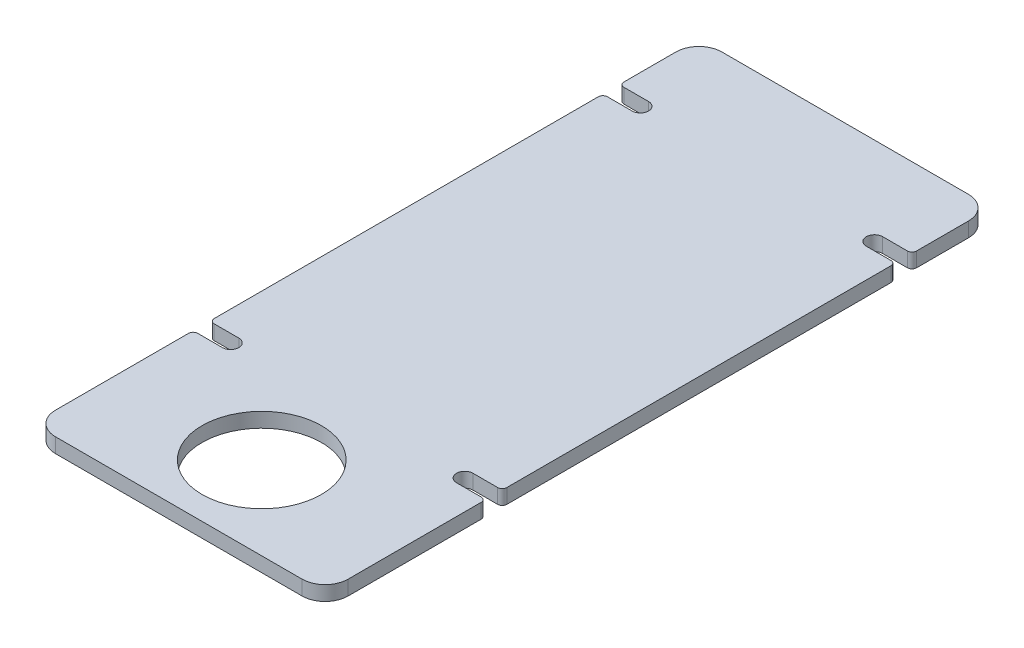
from build123d import *

# Parameters (mm, degrees)
SKETCH1_W           = 127
SKETCH1_H           = 289.2
SKETCH1_R           = 25.9
BOSS_EXTRUDE1_DEPTH = 6.35
CUT_EXTRUDE1_DEPTH  = 7.35
FILLET1_R           = 2
FILLET2_R           = 10


with BuildPart() as part:
    # Sketch1 → Boss-Extrude1 (new body)
    with BuildSketch(Plane(origin=(0, 0, 0), x_dir=(1, 0, 0), z_dir=(0, 1, 0))):
        with Locations((0, 108.6)):
            Rectangle(SKETCH1_W, SKETCH1_H)
        with Locations(Location((0, 0, 0), (0, 0, 270))):  # turned: the seam where the file's is
            Circle(SKETCH1_R, mode=Mode.SUBTRACT)
    extrude(amount=BOSS_EXTRUDE1_DEPTH)

    # Sketch3 → Cut-Extrude1 (cut, through all)
    with BuildSketch(Plane(origin=(0, 6.35, 0), x_dir=(1, 0, 0), z_dir=(0, 1, 0))):
        with BuildLine():
            Line((-76.2, 218.671875), (-50.8, 218.671875))
            ThreePointArc((-50.8, 218.671875), (-47.228125, 215.1), (-50.8, 211.528125))
            Line((-50.8, 211.528125), (-76.2, 211.528125))
            ThreePointArc((-76.2, 211.528125), (-79.771875, 215.1), (-76.2, 218.671875))
        make_face()
        with BuildLine():
            Line((-76.2, 40.871875), (-50.8, 40.871875))
            ThreePointArc((-50.8, 40.871875), (-47.228125, 37.3), (-50.8, 33.728125))
            Line((-50.8, 33.728125), (-76.2, 33.728125))
            ThreePointArc((-76.2, 33.728125), (-79.771875, 37.3), (-76.2, 40.871875))
        make_face()
    cut_extrude1 = extrude(amount=-CUT_EXTRUDE1_DEPTH, mode=Mode.SUBTRACT)

    # Mirror1: Cut-Extrude1 across plane
    add(cut_extrude1.mirror(Plane(origin=(0, 0, 0), x_dir=(0, 0, 1), z_dir=(1, 0, 0))), mode=Mode.SUBTRACT)

    # Fillet1
    fillet1_edges = [part.edges().sort_by_distance(p)[0] for p in [
        (-63.5, 3.175, -211.528125),
        (-63.5, 3.175, -218.671875),
        (-63.5, 3.175, -40.871875),
        (-63.5, 3.175, -33.728125),
        (63.5, 3.175, -218.671875),
        (63.5, 3.175, -211.528125),
        (63.5, 3.175, -33.728125),
        (63.5, 3.175, -40.871875),
    ]]
    fillet(fillet1_edges, radius=FILLET1_R)

    # Fillet2
    fillet2_edges = [part.edges().sort_by_distance(p)[0] for p in [
        (-63.5, 3.175, -253.2),
        (63.5, 3.175, -253.2),
        (63.5, 3.175, 36),
        (-63.5, 3.175, 36),
    ]]
    fillet(fillet2_edges, radius=FILLET2_R)


solid = part.part
